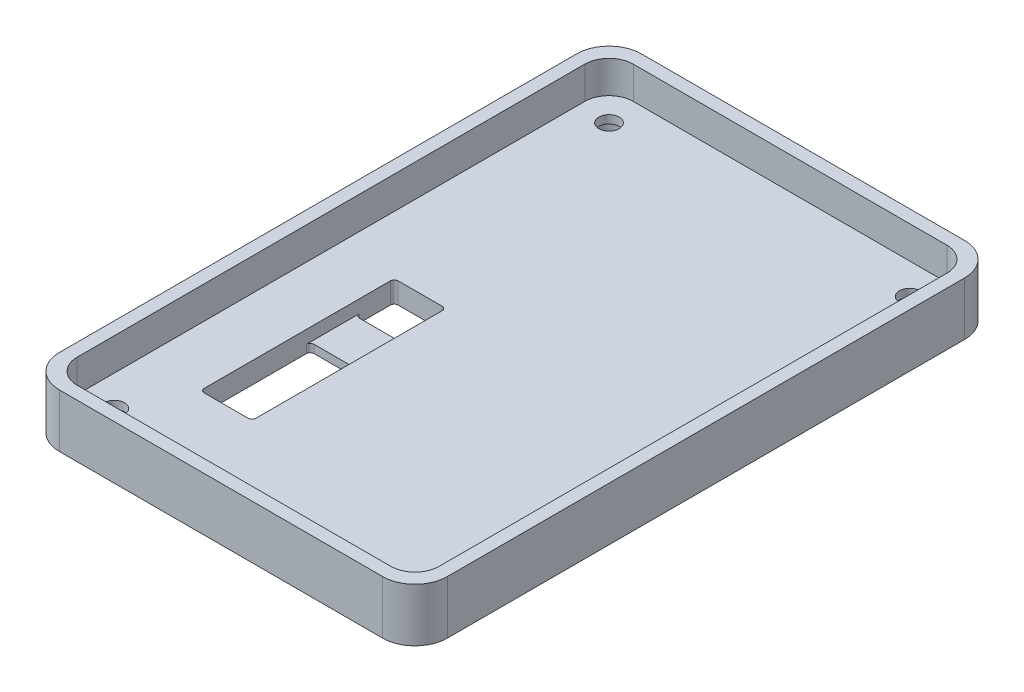
from build123d import *

# Parameters (mm, degrees)
SKETCH1_W           = 76.2
SKETCH1_H           = 114.3
BOSS_EXTRUDE1_DEPTH = 4.1275
SKETCH2_W           = 76.2
SKETCH2_H           = 114.3
SKETCH2_W_2         = 71.12
SKETCH2_H_2         = 109.22
BOSS_EXTRUDE2_DEPTH = 6.35
FILLET1_R           = 6.35
FILLET2_R           = 4.7625
SKETCH3_R           = 1.9939
CUT_EXTRUDE1_DEPTH  = 5.1275
SKETCH4_R           = 3.5052
CUT_EXTRUDE2_DEPTH  = 2.54
CUT_EXTRUDE3_DEPTH  = 3.175
SKETCH6_W           = 10.16
SKETCH6_H           = 21.59
SKETCH6_H_2         = 7.62
CUT_EXTRUDE4_DEPTH  = 11.4775
SKETCH7_W           = 10.16
SKETCH7_H           = 38.1
CUT_EXTRUDE5_DEPTH  = 2.54
FILLET3_R           = 0.762


with BuildPart() as part:
    # Sketch1 → Boss-Extrude1 (new body)
    with BuildSketch(Plane(origin=(0, 0, 0), x_dir=(1, 0, 0), z_dir=(0, 1, 0))):
        Rectangle(SKETCH1_W, SKETCH1_H)
    extrude(amount=BOSS_EXTRUDE1_DEPTH)

    # Sketch2 → Boss-Extrude2 (add)
    with BuildSketch(Plane(origin=(0, 4.1275, 0), x_dir=(1, 0, 0), z_dir=(0, 1, 0))):
        Rectangle(SKETCH2_W, SKETCH2_H)
        Rectangle(SKETCH2_W_2, SKETCH2_H_2, mode=Mode.SUBTRACT)
    extrude(amount=BOSS_EXTRUDE2_DEPTH)

    # Fillet1
    fillet1_edges = [part.edges().sort_by_distance(p)[0] for p in [
        (38.1, 5.23875, 57.15),
        (-38.1, 5.23875, 57.15),
        (-38.1, 5.23875, -57.15),
        (38.1, 5.23875, -57.15),
    ]]
    fillet(fillet1_edges, radius=FILLET1_R)

    # Fillet2
    fillet2_edges = [part.edges().sort_by_distance(p)[0] for p in [
        (-35.56, 7.3025, 54.61),
        (35.56, 7.3025, 54.61),
        (35.56, 7.3025, -54.61),
        (-35.56, 7.3025, -54.61),
    ]]
    fillet(fillet2_edges, radius=FILLET2_R)

    # Sketch3 → Cut-Extrude1 (cut, through all)
    with BuildSketch(Plane(origin=(0, 4.1275, 0), x_dir=(1, 0, 0), z_dir=(0, 1, 0))):
        with Locations((-29.5275, 48.5775)):
            Circle(SKETCH3_R)
        with Locations((29.5275, 48.5775)):
            Circle(SKETCH3_R)
        with Locations((29.5275, -48.5775)):
            Circle(SKETCH3_R)
        with Locations((-29.5275, -48.5775)):
            Circle(SKETCH3_R)
    extrude(amount=-CUT_EXTRUDE1_DEPTH, mode=Mode.SUBTRACT)

    # Sketch4 → Cut-Extrude2 (cut)
    with BuildSketch(Plane.XZ):
        with Locations((-29.5275, 48.5775)):
            Circle(SKETCH4_R)
        with Locations((29.5275, 48.5775)):
            Circle(SKETCH4_R)
        with Locations((29.5275, -48.5775)):
            Circle(SKETCH4_R)
        with Locations((-29.5275, -48.5775)):
            Circle(SKETCH4_R)
    extrude(amount=-CUT_EXTRUDE2_DEPTH, mode=Mode.SUBTRACT)

    # Sketch5 → Cut-Extrude3 (cut)
    with BuildSketch(Plane.XZ):
        with BuildLine():
            Line((14.373846154, 54.3), (15.074967949, 54.3))
            add(Edge.make_bspline(
                [(15.074967949, 54.3), (15.120778337, 54.299794943), (15.209156179, 54.299399345), (15.336604298, 54.294602193), (15.454181429, 54.286005403), (15.561860556, 54.275381131), (15.659597407, 54.260486316), (15.747514377, 54.243410575), (15.82562971, 54.222607354), (15.894824273, 54.197914219), (15.956924158, 54.168801977), (16.015690679, 54.137795361), (16.069795705, 54.100790059), (16.12197008, 54.061774345), (16.169230906, 54.017021062), (16.214526596, 53.969508606), (16.255938753, 53.917352673), (16.293659267, 53.861184597), (16.327877585, 53.802042122), (16.357772997, 53.73981952), (16.382022481, 53.67441833), (16.402364783, 53.606261623), (16.418703918, 53.535352371), (16.429579766, 53.461254473), (16.436967189, 53.384485311), (16.437619027, 53.332236171), (16.437948718, 53.305809295)],
                knots=[0, 0, 0, 0, 0.000137427, 0.000265126, 0.000382515, 0.000491069, 0.000589631, 0.000679006, 0.000759623, 0.000831924, 0.00089906, 0.000965255, 0.001030982, 0.001095489, 0.001160481, 0.001225953, 0.001292308, 0.00135998, 0.001428769, 0.001497134, 0.001566803, 0.001637786, 0.001710413, 0.00178488, 0.001862322, 0.001941576, 0.001941576, 0.001941576, 0.001941576], degree=3))
            add(Edge.make_bspline(
                [(16.437948718, 53.305809295), (16.437471697, 53.276573871), (16.436534292, 53.219122669), (16.427344706, 53.134906257), (16.411645989, 53.054613532), (16.391128587, 52.977567372), (16.36251853, 52.905035358), (16.329832882, 52.835286853), (16.289619169, 52.770277391), (16.243668572, 52.709193782), (16.193485278, 52.651539387), (16.137877937, 52.598978868), (16.07790645, 52.551153923), (16.01391797, 52.507563341), (15.945672265, 52.468295054), (15.873218577, 52.432981357), (15.796062152, 52.402751692), (15.742332739, 52.386941821), (15.715092147, 52.378926282)],
                knots=[0, 0, 0, 0, 8.7685e-05, 0.000172312, 0.000253715, 0.000332979, 0.000411103, 0.000487306, 0.000563783, 0.000639925, 0.000716434, 0.000792808, 0.000869127, 0.00094633, 0.001024859, 0.001105133, 0.00118794, 0.001273097, 0.001273097, 0.001273097, 0.001273097], degree=3))
            add(Edge.make_bspline(
                [(15.715092147, 52.378926282), (15.697149927, 52.374462228), (15.658281298, 52.364791651), (15.593964394, 52.354973587), (15.519845916, 52.345946482), (15.435686188, 52.338188777), (15.341436693, 52.332915346), (15.237188687, 52.32879703), (15.122894927, 52.32580259), (15.043419566, 52.325696334), (15.002051282, 52.325641026)],
                knots=[0, 0, 0, 0, 5.5442e-05, 0.000120105, 0.000194981, 0.000279468, 0.000373586, 0.000478137, 0.000592455, 0.000716555, 0.000716555, 0.000716555, 0.000716555], degree=3))
            Line((15.002051282, 52.325641026), (15.002051282, 50.8))
            Line((15.002051282, 50.8), (14.373846154, 50.8))
            Line((14.373846154, 50.8), (14.373846154, 54.3))
        make_face()
        with BuildLine():
            Line((15.002051282, 52.953846154), (15.224306891, 52.953846154))
            add(Edge.make_bspline(
                [(15.224306891, 52.953846154), (15.264749808, 52.954102593), (15.339165376, 52.954574446), (15.440790763, 52.961397707), (15.52245888, 52.971818204), (15.586978208, 52.986763608), (15.637922329, 53.009445236), (15.681858443, 53.035683609), (15.719543571, 53.068861312), (15.752173344, 53.106772514), (15.778259865, 53.150334385), (15.796349508, 53.198837605), (15.808100185, 53.251263069), (15.809185469, 53.287747722), (15.80974359, 53.306510417)],
                knots=[0, 0, 0, 0, 0.000121312, 0.000223216, 0.000305317, 0.000368234, 0.000420986, 0.000471971, 0.000521175, 0.00057091, 0.000621531, 0.000672574, 0.000725656, 0.000781855, 0.000781855, 0.000781855, 0.000781855], degree=3))
            add(Edge.make_bspline(
                [(15.80974359, 53.306510417), (15.80919121, 53.322903138), (15.80811946, 53.354708959), (15.800246092, 53.400612649), (15.787698208, 53.443404356), (15.769516806, 53.48263718), (15.74601256, 53.518244457), (15.717356126, 53.550212159), (15.683915225, 53.579224904), (15.658096894, 53.594581793), (15.644979968, 53.602383814)],
                knots=[0, 0, 0, 0, 4.9159e-05, 9.5379e-05, 0.000139299, 0.000182587, 0.00022459, 0.000266803, 0.000311063, 0.000356771, 0.000356771, 0.000356771, 0.000356771], degree=3))
            add(Edge.make_bspline(
                [(15.644979968, 53.602383814), (15.633869174, 53.608002861), (15.610345348, 53.619899535), (15.57028199, 53.633730288), (15.524049488, 53.645398051), (15.471335718, 53.655082183), (15.412350972, 53.662598074), (15.347105774, 53.668345851), (15.275504108, 53.670657256), (15.225709434, 53.671405207), (15.199767628, 53.671794872)],
                knots=[0, 0, 0, 0, 3.7318e-05, 7.901e-05, 0.000126794, 0.000180286, 0.000239683, 0.000305129, 0.000376698, 0.000454535, 0.000454535, 0.000454535, 0.000454535], degree=3))
            Line((15.199767628, 53.671794872), (15.002051282, 53.671794872))
            Line((15.002051282, 53.671794872), (15.002051282, 52.953846154))
        make_face(mode=Mode.SUBTRACT)
        Polygon((16.729615385, 54.3), (17.378153045, 54.3), (17.896282051, 52.06552484), (18.490132212, 54.3), (19.100809295, 54.3), (19.691153846, 52.06552484), (20.207880609, 54.3), (20.857820513, 54.3), (20.04802484, 50.8), (19.39177484, 50.8), (18.793717949, 53.062520032), (18.192155449, 50.8), (17.540813301, 50.8), align=None)
        with BuildLine():
            Line((21.418717949, 54.3), (22.150689103, 54.3))
            add(Edge.make_bspline(
                [(22.150689103, 54.3), (22.199072173, 54.299828268), (22.292126446, 54.299497979), (22.426305626, 54.294286889), (22.549567655, 54.28703523), (22.662095034, 54.275969006), (22.763839622, 54.26129653), (22.854903391, 54.244000109), (22.93528368, 54.22428713), (23.005658384, 54.199723202), (23.069168074, 54.172015463), (23.128367935, 54.140178764), (23.184564004, 54.104567615), (23.23738067, 54.064244991), (23.287276923, 54.019936286), (23.334346895, 53.971596899), (23.377925444, 53.918816932), (23.417742729, 53.861929887), (23.45403298, 53.80208602), (23.48610595, 53.739203166), (23.512187742, 53.673237592), (23.535233802, 53.605142645), (23.551833132, 53.533944894), (23.563377723, 53.460337461), (23.571830222, 53.38406124), (23.5723162, 53.332242562), (23.572564103, 53.305809295)],
                knots=[0, 0, 0, 0, 0.000145139, 0.000279143, 0.000402781, 0.00051552, 0.000618244, 0.00071106, 0.000793533, 0.000866261, 0.000934389, 0.001001202, 0.00106772, 0.001133767, 0.001200318, 0.00126775, 0.001335975, 0.001405418, 0.00147588, 0.001545802, 0.001616889, 0.001688503, 0.001761288, 0.001835865, 0.001911978, 0.001991232, 0.001991232, 0.001991232, 0.001991232], degree=3))
            add(Edge.make_bspline(
                [(23.572564103, 53.305809295), (23.57192014, 53.278219036), (23.570657448, 53.224119568), (23.563855899, 53.144651861), (23.551424805, 53.068622717), (23.532596105, 52.996254741), (23.510954959, 52.926647229), (23.482177787, 52.861084482), (23.449699903, 52.798612986), (23.41112687, 52.740116424), (23.36879485, 52.684295469), (23.319563602, 52.633288831), (23.266622554, 52.584355094), (23.206995697, 52.540559303), (23.143311437, 52.498940145), (23.074304437, 52.461222103), (23.000425059, 52.426457035), (22.948484197, 52.407069631), (22.921923077, 52.397155449)],
                knots=[0, 0, 0, 0, 8.278e-05, 0.000162316, 0.000239082, 0.000313563, 0.00038651, 0.000457489, 0.000528056, 0.000597481, 0.00066746, 0.000737887, 0.000809857, 0.000883475, 0.000959513, 0.001037964, 0.001119203, 0.001204224, 0.001204224, 0.001204224, 0.001204224], degree=3))
            Line((22.921923077, 52.397155449), (23.729615385, 50.8))
            Line((23.729615385, 50.8), (23.031298077, 50.8))
            Line((23.031298077, 50.8), (22.260064103, 52.325641026))
            Line((22.260064103, 52.325641026), (22.046923077, 52.325641026))
            Line((22.046923077, 52.325641026), (22.046923077, 50.8))
            Line((22.046923077, 50.8), (21.418717949, 50.8))
            Line((21.418717949, 50.8), (21.418717949, 54.3))
        make_face()
        with BuildLine():
            Line((22.046923077, 52.953846154), (22.291614583, 52.953846154))
            add(Edge.make_bspline(
                [(22.291614583, 52.953846154), (22.321530154, 52.954183083), (22.378812044, 52.95482823), (22.461190925, 52.95782069), (22.536010595, 52.96503104), (22.603592355, 52.974141047), (22.664276271, 52.984659866), (22.717521063, 52.999733972), (22.764147153, 53.015886258), (22.803602019, 53.03595936), (22.83731135, 53.058786831), (22.866417199, 53.084719405), (22.89049191, 53.114733058), (22.910306625, 53.148012147), (22.925720319, 53.184851019), (22.936971135, 53.224845265), (22.943258678, 53.268450472), (22.943982081, 53.298544002), (22.944358974, 53.314222756)],
                knots=[0, 0, 0, 0, 8.9755e-05, 0.000171861, 0.000247208, 0.00031513, 0.000376461, 0.000431743, 0.000480981, 0.000524253, 0.000564118, 0.000602839, 0.000640725, 0.000679082, 0.000718669, 0.000760178, 0.000803409, 0.000850432, 0.000850432, 0.000850432, 0.000850432], degree=3))
            add(Edge.make_bspline(
                [(22.944358974, 53.314222756), (22.943646422, 53.332771868), (22.942246746, 53.369208159), (22.928357609, 53.421663643), (22.906249102, 53.470214782), (22.875944395, 53.51464221), (22.837779556, 53.55359036), (22.793982392, 53.587923465), (22.743607655, 53.615071516), (22.696964439, 53.632978081), (22.654530015, 53.643691763), (22.616234286, 53.651675505), (22.571887601, 53.657333812), (22.521456482, 53.663335453), (22.465069478, 53.667227214), (22.402419246, 53.670067423), (22.333685719, 53.671229493), (22.285771922, 53.671600986), (22.260765224, 53.671794872)],
                knots=[0, 0, 0, 0, 5.5548e-05, 0.000109114, 0.000161511, 0.00021499, 0.000269533, 0.000324507, 0.000381303, 0.00044055, 0.000473881, 0.00051252, 0.000557833, 0.000607927, 0.000664874, 0.000727337, 0.000796061, 0.000871084, 0.000871084, 0.000871084, 0.000871084], degree=3))
            Line((22.260765224, 53.671794872), (22.046923077, 53.671794872))
            Line((22.046923077, 53.671794872), (22.046923077, 52.953846154))
        make_face(mode=Mode.SUBTRACT)
        with BuildLine():
            Line((1.673846154, 54.3), (2.302051282, 54.3))
            Line((2.302051282, 54.3), (2.302051282, 52.02275641))
            add(Edge.make_bspline(
                [(2.302051282, 52.02275641), (2.302085441, 51.999146936), (2.302151418, 51.953545482), (2.305454269, 51.888122324), (2.308476606, 51.827984744), (2.31392976, 51.77319858), (2.321985937, 51.723740395), (2.329786945, 51.679292488), (2.340344838, 51.640650649), (2.356211663, 51.59666612), (2.380657232, 51.547247098), (2.420599935, 51.49574146), (2.466690398, 51.44873509), (2.521932472, 51.409608768), (2.584019678, 51.377959101), (2.652610874, 51.3545102), (2.72760937, 51.341475724), (2.779466717, 51.339485773), (2.806157853, 51.338461538)],
                knots=[0, 0, 0, 0, 7.0817e-05, 0.000136782, 0.00019648, 0.000251455, 0.000301828, 0.000346793, 0.000386763, 0.000421805, 0.000487025, 0.000551107, 0.000616549, 0.000683871, 0.000753169, 0.000825005, 0.000900509, 0.000980587, 0.000980587, 0.000980587, 0.000980587], degree=3))
            add(Edge.make_bspline(
                [(2.806157853, 51.338461538), (2.83451389, 51.339288988), (2.889803363, 51.340902375), (2.969328467, 51.356739513), (3.043008927, 51.38195766), (3.109284676, 51.417950384), (3.16808976, 51.461093971), (3.217867031, 51.51029118), (3.25715107, 51.565640135), (3.282754946, 51.616703761), (3.297130261, 51.663703381), (3.307905275, 51.705695759), (3.315804553, 51.755242608), (3.322971038, 51.811570148), (3.327277543, 51.875261823), (3.331947246, 51.945805416), (3.333658735, 52.023683606), (3.333950446, 52.077911652), (3.334102564, 52.106189904)],
                knots=[0, 0, 0, 0, 8.4978e-05, 0.000165692, 0.000242191, 0.000317789, 0.000390988, 0.000460396, 0.00052674, 0.000593843, 0.00063065, 0.000674012, 0.000723806, 0.000781028, 0.00084432, 0.000915258, 0.000993111, 0.00107795, 0.00107795, 0.00107795, 0.00107795], degree=3))
            Line((3.334102564, 52.106189904), (3.334102564, 54.3))
            Line((3.334102564, 54.3), (3.962307692, 54.3))
            Line((3.962307692, 54.3), (3.962307692, 52.212059295))
            add(Edge.make_bspline(
                [(3.962307692, 52.212059295), (3.962220455, 52.169757716), (3.962052705, 52.088415905), (3.959476577, 51.971521999), (3.953992467, 51.864758166), (3.949386446, 51.768093211), (3.94047222, 51.681657357), (3.931185687, 51.605081498), (3.919349202, 51.538637002), (3.901737224, 51.462998018), (3.871344164, 51.375902498), (3.822346567, 51.275615782), (3.760147289, 51.177429012), (3.68663085, 51.082422312), (3.603624066, 50.994164148), (3.512967375, 50.916684905), (3.416101086, 50.85114582), (3.312013016, 50.799149403), (3.200791749, 50.758596117), (3.081336834, 50.731346352), (2.953729729, 50.712936068), (2.86558909, 50.711167534), (2.820180288, 50.71025641)],
                knots=[0, 0, 0, 0, 0.000126905, 0.000244026, 0.000350709, 0.000447627, 0.000534274, 0.000611324, 0.000678989, 0.000736639, 0.000844176, 0.000954866, 0.001070804, 0.001192252, 0.001314756, 0.001433618, 0.00154932, 0.001664708, 0.001781814, 0.001903577, 0.002031685, 0.002167818, 0.002167818, 0.002167818, 0.002167818], degree=3))
            add(Edge.make_bspline(
                [(2.820180288, 50.71025641), (2.790009777, 50.710764593), (2.730483977, 50.711767226), (2.642940845, 50.720607835), (2.558313212, 50.733635567), (2.476760091, 50.752641687), (2.397998428, 50.777194045), (2.322049147, 50.807416287), (2.249194494, 50.843139837), (2.179842153, 50.884036118), (2.114077469, 50.928258405), (2.053971943, 50.977280672), (1.997457202, 51.027477536), (1.946165934, 51.080961496), (1.899712895, 51.137171061), (1.858193755, 51.196233619), (1.821670199, 51.258143926), (1.789223496, 51.32401791), (1.761452285, 51.397203708), (1.738040111, 51.480304569), (1.717586684, 51.574623017), (1.702386905, 51.680371546), (1.688606695, 51.79720162), (1.679884582, 51.925417599), (1.675321653, 52.065023163), (1.674350415, 52.161808806), (1.673846154, 52.212059295)],
                knots=[0, 0, 0, 0, 9.0488e-05, 0.000178531, 0.000263714, 0.000347218, 0.000429489, 0.000510991, 0.000592203, 0.000672649, 0.00075238, 0.000829685, 0.000905146, 0.00097903, 0.001051744, 0.001123714, 0.00119538, 0.001267186, 0.001343749, 0.001429848, 0.001525973, 0.001633063, 0.00175021, 0.001878838, 0.002018448, 0.002169204, 0.002169204, 0.002169204, 0.002169204], degree=3))
            Line((1.673846154, 52.212059295), (1.673846154, 54.3))
        make_face()
        with BuildLine():
            Line((6.564871795, 53.832351763), (6.095120192, 53.402564103))
            add(Edge.make_bspline(
                [(6.095120192, 53.402564103), (6.074998048, 53.430948479), (6.036366337, 53.485442524), (5.973748362, 53.558411334), (5.91141314, 53.62065916), (5.848783173, 53.671925958), (5.785303331, 53.711900244), (5.721083807, 53.740202481), (5.65648868, 53.758194481), (5.613090725, 53.760434918), (5.591714744, 53.761538462)],
                knots=[0, 0, 0, 0, 0.000104333, 0.000200305, 0.000288057, 0.000368319, 0.000442638, 0.000512332, 0.000578316, 0.000642364, 0.000642364, 0.000642364, 0.000642364], degree=3))
            add(Edge.make_bspline(
                [(5.591714744, 53.761538462), (5.571775841, 53.760839206), (5.533279059, 53.759489126), (5.478399039, 53.746069437), (5.429675777, 53.722909025), (5.387156823, 53.692624837), (5.353475538, 53.656139412), (5.326583643, 53.617875583), (5.311441247, 53.575640968), (5.30944821, 53.546632532), (5.308461538, 53.532271635)],
                knots=[0, 0, 0, 0, 5.9744e-05, 0.000115349, 0.000168041, 0.000220774, 0.000270869, 0.000316372, 0.00036028, 0.000403329, 0.000403329, 0.000403329, 0.000403329], degree=3))
            add(Edge.make_bspline(
                [(5.308461538, 53.532271635), (5.309079836, 53.517703647), (5.310325, 53.488365745), (5.322351594, 53.445367395), (5.340479105, 53.403353002), (5.357800682, 53.377776842), (5.366654647, 53.364703526)],
                knots=[0, 0, 0, 0, 4.3611e-05, 8.7826e-05, 0.000133031, 0.000180298, 0.000180298, 0.000180298, 0.000180298], degree=3))
            add(Edge.make_bspline(
                [(5.366654647, 53.364703526), (5.37470386, 53.354541774), (5.393232084, 53.331150764), (5.428561614, 53.29410305), (5.472928082, 53.248716357), (5.528038806, 53.196551401), (5.591605987, 53.135732126), (5.666576045, 53.068649361), (5.750791017, 52.993225631), (5.810649067, 52.940703276), (5.842015224, 52.91318109)],
                knots=[0, 0, 0, 0, 3.8873e-05, 8.948e-05, 0.000153436, 0.000229303, 0.000317089, 0.000417357, 0.00053107, 0.000656255, 0.000656255, 0.000656255, 0.000656255], degree=3))
            add(Edge.make_bspline(
                [(5.842015224, 52.91318109), (5.871456875, 52.887700826), (5.927331011, 52.83934458), (6.00682881, 52.770710653), (6.076694136, 52.708962381), (6.137944766, 52.655026476), (6.189652201, 52.608337026), (6.232033819, 52.568670855), (6.265607238, 52.536800191), (6.284691762, 52.517550291), (6.292836538, 52.509334936)],
                knots=[0, 0, 0, 0, 0.00011681, 0.000221681, 0.000315075, 0.000396532, 0.000466521, 0.000524065, 0.000570677, 0.000605381, 0.000605381, 0.000605381, 0.000605381], degree=3))
            add(Edge.make_bspline(
                [(6.292836538, 52.509334936), (6.323736123, 52.475894968), (6.383135976, 52.411611605), (6.460334845, 52.311992611), (6.523872011, 52.214744159), (6.573025567, 52.118036363), (6.61014831, 52.020473922), (6.636320336, 51.919664122), (6.651994936, 51.814553564), (6.653735183, 51.742828439), (6.654615385, 51.706550481)],
                knots=[0, 0, 0, 0, 0.000136539, 0.000262476, 0.000377607, 0.00048453, 0.00058727, 0.000690153, 0.000796447, 0.000905231, 0.000905231, 0.000905231, 0.000905231], degree=3))
            add(Edge.make_bspline(
                [(6.654615385, 51.706550481), (6.653988879, 51.671202059), (6.652759653, 51.601847141), (6.637703985, 51.500356549), (6.616235487, 51.403225647), (6.583041422, 51.311511358), (6.542584692, 51.223708218), (6.491866339, 51.141183923), (6.432304587, 51.063103292), (6.364037674, 50.990862112), (6.288526362, 50.925308248), (6.207533304, 50.86695065), (6.120266508, 50.81876902), (6.027471568, 50.779094884), (5.929198156, 50.748537334), (5.825563344, 50.725952457), (5.716408616, 50.712397369), (5.64176704, 50.710980346), (5.603633814, 50.71025641)],
                knots=[0, 0, 0, 0, 0.000105953, 0.000207884, 0.000307206, 0.000403889, 0.000499869, 0.000596786, 0.000693825, 0.000794014, 0.0008944, 0.000993427, 0.001092919, 0.001192806, 0.001295697, 0.001401176, 0.001510663, 0.001625023, 0.001625023, 0.001625023, 0.001625023], degree=3))
            add(Edge.make_bspline(
                [(5.603633814, 50.71025641), (5.573699556, 50.710787464), (5.514412559, 50.711839255), (5.427032487, 50.720426251), (5.34265715, 50.734284751), (5.26138159, 50.75414812), (5.182839644, 50.779317702), (5.107028088, 50.810061383), (5.034470274, 50.846855678), (4.964617195, 50.88894395), (4.897808424, 50.937813977), (4.833199189, 50.992466629), (4.771431251, 51.053742487), (4.712207951, 51.121496636), (4.655908216, 51.19592094), (4.600689154, 51.275978902), (4.549004866, 51.36315629), (4.517077183, 51.424311933), (4.500769231, 51.455548878)],
                knots=[0, 0, 0, 0, 8.9787e-05, 0.000177831, 0.000263126, 0.00034611, 0.000428593, 0.000510357, 0.000591254, 0.000672417, 0.000754739, 0.000839305, 0.000926065, 0.001015502, 0.001109035, 0.001205881, 0.001307125, 0.001412829, 0.001412829, 0.001412829, 0.001412829], degree=3))
            Line((4.500769231, 51.455548878), (5.053253205, 51.787179487))
            add(Edge.make_bspline(
                [(5.053253205, 51.787179487), (5.073652016, 51.751721473), (5.112758279, 51.68374543), (5.179027498, 51.592411001), (5.24691693, 51.514198182), (5.317996118, 51.450489388), (5.391400765, 51.400432751), (5.467485432, 51.364658806), (5.546303576, 51.342514774), (5.599990915, 51.339810476), (5.626770833, 51.338461538)],
                knots=[0, 0, 0, 0, 0.000122646, 0.000235123, 0.000337949, 0.000432798, 0.000520693, 0.0006035, 0.000684117, 0.000764351, 0.000764351, 0.000764351, 0.000764351], degree=3))
            add(Edge.make_bspline(
                [(5.626770833, 51.338461538), (5.654009844, 51.339563154), (5.706857493, 51.341700449), (5.782290748, 51.361441996), (5.851450813, 51.392437673), (5.911232262, 51.43666423), (5.961851424, 51.487708399), (5.999211271, 51.544497371), (6.022680979, 51.605941668), (6.025162296, 51.648624918), (6.026410256, 51.670092147)],
                knots=[0, 0, 0, 0, 8.1575e-05, 0.000158267, 0.000232307, 0.000307618, 0.000380007, 0.000446905, 0.00051034, 0.000574526, 0.000574526, 0.000574526, 0.000574526], degree=3))
            add(Edge.make_bspline(
                [(6.026410256, 51.670092147), (6.025257816, 51.690063911), (6.022916744, 51.730634636), (6.005673128, 51.79095678), (5.978716097, 51.851251492), (5.946824028, 51.900706845), (5.914369855, 51.942114472), (5.883336345, 51.977992307), (5.84554574, 52.017631034), (5.801093859, 52.061080516), (5.750568027, 52.108723248), (5.693925685, 52.160554566), (5.630518215, 52.216117898), (5.585701691, 52.25396709), (5.562267628, 52.273758013)],
                knots=[0, 0, 0, 0, 5.9859e-05, 0.000121597, 0.000186877, 0.000257482, 0.000297452, 0.000344677, 0.000399728, 0.000461701, 0.000531137, 0.000608059, 0.000692021, 0.000784039, 0.000784039, 0.000784039, 0.000784039], degree=3))
            add(Edge.make_bspline(
                [(5.562267628, 52.273758013), (5.517718542, 52.311450812), (5.432215361, 52.383794702), (5.311388519, 52.49064435), (5.202512715, 52.590505137), (5.106528318, 52.68461156), (5.022212339, 52.771225691), (4.950135801, 52.851051045), (4.891090499, 52.924703364), (4.828958051, 53.011939606), (4.769919802, 53.118242962), (4.718894001, 53.246138223), (4.685790616, 53.374017255), (4.682081842, 53.459868194), (4.68025641, 53.502123397)],
                knots=[0, 0, 0, 0, 0.000175062, 0.000335996, 0.000483855, 0.000618216, 0.0007392, 0.000846451, 0.000940727, 0.001022233, 0.001167556, 0.001304131, 0.00143473, 0.001561313, 0.001561313, 0.001561313, 0.001561313], degree=3))
            add(Edge.make_bspline(
                [(4.68025641, 53.502123397), (4.681015605, 53.53208852), (4.682511299, 53.59112303), (4.695853127, 53.677924675), (4.715792996, 53.761680969), (4.744751411, 53.842086331), (4.782335936, 53.919040051), (4.827980883, 53.992918848), (4.88239503, 54.063042759), (4.9437161, 54.129365297), (5.011276219, 54.189976549), (5.083472792, 54.243472052), (5.15989718, 54.288655132), (5.240081857, 54.326137778), (5.324523695, 54.354828362), (5.412600613, 54.375165678), (5.504438943, 54.387261665), (5.566905392, 54.388905974), (5.598725962, 54.38974359)],
                knots=[0, 0, 0, 0, 8.9842e-05, 0.000176999, 0.000262874, 0.000347814, 0.000432791, 0.000519374, 0.000607862, 0.000698654, 0.00079001, 0.000879756, 0.000967774, 0.001055918, 0.001144828, 0.001234796, 0.001326718, 0.001422163, 0.001422163, 0.001422163, 0.001422163], degree=3))
            add(Edge.make_bspline(
                [(5.598725962, 54.38974359), (5.639963844, 54.38823502), (5.722114092, 54.385229789), (5.843575603, 54.361729864), (5.962214128, 54.324773756), (6.057815275, 54.280190278), (6.133883324, 54.237002242), (6.192182377, 54.197240139), (6.251504802, 54.151690512), (6.312328997, 54.100209824), (6.373524754, 54.04182811), (6.436832161, 53.977935192), (6.501388578, 53.907978887), (6.543340014, 53.858002427), (6.564871795, 53.832351763)],
                knots=[0, 0, 0, 0, 0.000123638, 0.0002463, 0.000369811, 0.000495611, 0.000561878, 0.000632077, 0.000707101, 0.000786191, 0.000871003, 0.000960739, 0.001056009, 0.001156468, 0.001156468, 0.001156468, 0.001156468], degree=3))
        make_face()
        with BuildLine():
            Line((7.282820513, 50.8), (7.282820513, 54.3))
            Line((7.282820513, 54.3), (7.843717949, 54.3))
            add(Edge.make_bspline(
                [(7.843717949, 54.3), (7.882984276, 54.300004481), (7.958963876, 54.300013152), (8.068582609, 54.296163702), (8.170244727, 54.291184008), (8.2636267, 54.285612887), (8.348887473, 54.276012733), (8.42589739, 54.26589522), (8.49481032, 54.253694122), (8.53741544, 54.242749359), (8.557459936, 54.23760016)],
                knots=[0, 0, 0, 0, 0.000117791, 0.000227922, 0.000329003, 0.000423165, 0.000508489, 0.000586326, 0.000656186, 0.000718254, 0.000718254, 0.000718254, 0.000718254], degree=3))
            add(Edge.make_bspline(
                [(8.557459936, 54.23760016), (8.583780394, 54.230337123), (8.635429583, 54.216084712), (8.709407704, 54.187301353), (8.779586272, 54.155306608), (8.845879599, 54.118806588), (8.907880619, 54.077360636), (8.965353706, 54.030639824), (9.019538413, 53.980519523), (9.068510765, 53.925602894), (9.112773703, 53.867573304), (9.151230259, 53.806445956), (9.184644078, 53.743155529), (9.211383885, 53.676905554), (9.231531828, 53.60800113), (9.246267948, 53.53673649), (9.25581895, 53.462886135), (9.256721395, 53.412643325), (9.257179487, 53.387139423)],
                knots=[0, 0, 0, 0, 8.1863e-05, 0.000160642, 0.000237816, 0.000313134, 0.000387417, 0.000461218, 0.000535129, 0.000608609, 0.000681668, 0.000753832, 0.000825019, 0.000896106, 0.000967761, 0.001040089, 0.001114269, 0.001190743, 0.001190743, 0.001190743, 0.001190743], degree=3))
            add(Edge.make_bspline(
                [(9.257179487, 53.387139423), (9.255981711, 53.354373604), (9.253624037, 53.289878115), (9.238563053, 53.195145911), (9.210321361, 53.105610361), (9.173367794, 53.019621361), (9.123122496, 52.937499648), (9.059320685, 52.859284271), (8.982995742, 52.782566859), (8.924450297, 52.736579946), (8.893998397, 52.712660256)],
                knots=[0, 0, 0, 0, 9.8317e-05, 0.000193525, 0.000286672, 0.000379289, 0.00047368, 0.000574417, 0.000681503, 0.000797579, 0.000797579, 0.000797579, 0.000797579], degree=3))
            add(Edge.make_bspline(
                [(8.893998397, 52.712660256), (8.918675156, 52.700062985), (8.967059452, 52.675363221), (9.035750939, 52.634764183), (9.099351757, 52.591581957), (9.158147074, 52.546685387), (9.21090359, 52.498171241), (9.25979971, 52.448834973), (9.302423155, 52.395849818), (9.340538324, 52.341104269), (9.373667409, 52.283805604), (9.402519189, 52.224050586), (9.426889252, 52.161635081), (9.447526453, 52.096876733), (9.462917682, 52.029552802), (9.472953091, 51.959639212), (9.480636827, 51.887374403), (9.48123455, 51.838149419), (9.481538462, 51.813120994)],
                knots=[0, 0, 0, 0, 8.3106e-05, 0.000162948, 0.000239177, 0.000313644, 0.000384624, 0.000454039, 0.000521819, 0.000588334, 0.000653992, 0.000720158, 0.00078721, 0.000854842, 0.000923894, 0.000994098, 0.001066653, 0.001141702, 0.001141702, 0.001141702, 0.001141702], degree=3))
            add(Edge.make_bspline(
                [(9.481538462, 51.813120994), (9.479566277, 51.765318131), (9.475674179, 51.670979375), (9.447217058, 51.532468413), (9.397881453, 51.401147459), (9.331633909, 51.277538437), (9.250004188, 51.165219626), (9.156153417, 51.066829323), (9.051026459, 50.983544116), (8.954034135, 50.927333062), (8.870143412, 50.889610189), (8.800658294, 50.86628753), (8.726032749, 50.844681453), (8.644899819, 50.82950922), (8.55873033, 50.815621925), (8.466684127, 50.80704762), (8.368933241, 50.801237026), (8.301793707, 50.800420678), (8.267195513, 50.8)],
                knots=[0, 0, 0, 0, 0.000143365, 0.000282931, 0.000422024, 0.000562867, 0.000702406, 0.000837288, 0.000969562, 0.001103403, 0.001172455, 0.001245183, 0.001323096, 0.001405322, 0.001492583, 0.001584881, 0.001682498, 0.001786285, 0.001786285, 0.001786285, 0.001786285], degree=3))
            Line((8.267195513, 50.8), (7.282820513, 50.8))
        make_face()
        with BuildLine():
            Line((7.911025641, 53.671794872), (7.911025641, 52.908974359))
            Line((7.911025641, 52.908974359), (8.077892628, 52.908974359))
            add(Edge.make_bspline(
                [(8.077892628, 52.908974359), (8.100571351, 52.909172126), (8.144351253, 52.909553903), (8.207586677, 52.914471063), (8.26638541, 52.922860042), (8.320524439, 52.934564777), (8.370508091, 52.949428086), (8.416017055, 52.967311846), (8.456851236, 52.989131978), (8.50429111, 53.021634027), (8.554438478, 53.069462248), (8.598582641, 53.138560023), (8.624583259, 53.2180222), (8.627479027, 53.274065081), (8.628974359, 53.303004808)],
                knots=[0, 0, 0, 0, 6.8023e-05, 0.000131315, 0.000190113, 0.000246084, 0.000297324, 0.000346407, 0.000392516, 0.000435884, 0.000518691, 0.000598437, 0.000679585, 0.000766233, 0.000766233, 0.000766233, 0.000766233], degree=3))
            add(Edge.make_bspline(
                [(8.628974359, 53.303004808), (8.627777819, 53.33011167), (8.625464358, 53.3825217), (8.599285079, 53.456110049), (8.558623483, 53.521324387), (8.510616754, 53.565958269), (8.46540909, 53.596441894), (8.426699514, 53.616514062), (8.384212847, 53.634482463), (8.337126594, 53.64822154), (8.285709642, 53.658530859), (8.230211753, 53.66610182), (8.170537173, 53.671254938), (8.129319814, 53.671611033), (8.108040865, 53.671794872)],
                knots=[0, 0, 0, 0, 8.0997e-05, 0.000156604, 0.000231296, 0.000309653, 0.000351072, 0.000394666, 0.000440239, 0.000489262, 0.000541514, 0.000597437, 0.000657234, 0.000721051, 0.000721051, 0.000721051, 0.000721051], degree=3))
            Line((8.108040865, 53.671794872), (7.911025641, 53.671794872))
        make_face(mode=Mode.SUBTRACT)
        with BuildLine():
            Line((7.911025641, 52.325641026), (7.911025641, 51.428205128))
            Line((7.911025641, 51.428205128), (8.091915064, 51.428205128))
            add(Edge.make_bspline(
                [(8.091915064, 51.428205128), (8.127677133, 51.428409436), (8.196434174, 51.428802242), (8.294928513, 51.433548278), (8.384484491, 51.442102171), (8.464864818, 51.452781017), (8.536192611, 51.467249184), (8.598226767, 51.485643603), (8.651818003, 51.505880669), (8.696644982, 51.530875847), (8.733266057, 51.559964037), (8.766312737, 51.589692865), (8.793256941, 51.623987877), (8.814575698, 51.661376883), (8.833027044, 51.700931114), (8.844155593, 51.744195147), (8.85262848, 51.78988674), (8.853094766, 51.821490627), (8.853333333, 51.837660256)],
                knots=[0, 0, 0, 0, 0.000107281, 0.000206261, 0.0002957, 0.000377105, 0.000449433, 0.000513769, 0.000571055, 0.000620973, 0.00066697, 0.000711118, 0.000754041, 0.00079709, 0.000840088, 0.000884486, 0.000930707, 0.00097913, 0.00097913, 0.00097913, 0.00097913], degree=3))
            add(Edge.make_bspline(
                [(8.853333333, 51.837660256), (8.852807223, 51.856150482), (8.851782502, 51.892164468), (8.843413592, 51.944802751), (8.828204549, 51.993944081), (8.809048016, 52.040845068), (8.782390684, 52.083826493), (8.750709356, 52.12437578), (8.712430223, 52.161119805), (8.669383106, 52.196280985), (8.619172905, 52.227066502), (8.561776064, 52.253778392), (8.496880771, 52.276087179), (8.424286008, 52.293849449), (8.344310023, 52.308924042), (8.256369079, 52.317925239), (8.161195581, 52.324619824), (8.095200728, 52.32529289), (8.061065705, 52.325641026)],
                knots=[0, 0, 0, 0, 5.546e-05, 0.00010802, 0.00015926, 0.000209526, 0.000259547, 0.000310464, 0.000363513, 0.000418371, 0.000476935, 0.000539665, 0.000607959, 0.000682439, 0.000763712, 0.0008519, 0.000947461, 0.001049847, 0.001049847, 0.001049847, 0.001049847], degree=3))
            Line((8.061065705, 52.325641026), (7.911025641, 52.325641026))
        make_face(mode=Mode.SUBTRACT)
    extrude(amount=-CUT_EXTRUDE3_DEPTH, mode=Mode.SUBTRACT)

    # Sketch6 → Cut-Extrude4 (cut, through all)
    with BuildSketch(Plane.XZ):
        with Locations((-19.05, 26.289)):
            Rectangle(SKETCH6_W, SKETCH6_H)
        with Locations((-19.05, 2.794)):
            Rectangle(SKETCH6_W, SKETCH6_H_2)
    extrude(amount=-CUT_EXTRUDE4_DEPTH, mode=Mode.SUBTRACT)

    # Sketch7 → Cut-Extrude5 (cut)
    with BuildSketch(Plane(origin=(0, 4.1275, 0), x_dir=(1, 0, 0), z_dir=(0, 1, 0))):
        with Locations((-19.05, -18.034)):
            Rectangle(SKETCH7_W, SKETCH7_H)
    extrude(amount=-CUT_EXTRUDE5_DEPTH, mode=Mode.SUBTRACT)

    # Fillet3
    fillet3_edges = [part.edges().sort_by_distance(p)[0] for p in [
        (-24.13, 2.06375, 37.084),
        (-13.97, 2.06375, 37.084),
        (-24.13, 2.06375, -1.016),
        (-13.97, 2.06375, -1.016),
        (-24.13, 0.79375, 15.494),
        (-13.97, 0.79375, 15.494),
        (-13.97, 0.79375, 6.604),
        (-24.13, 0.79375, 6.604),
    ]]
    fillet(fillet3_edges, radius=FILLET3_R)


solid = part.part
